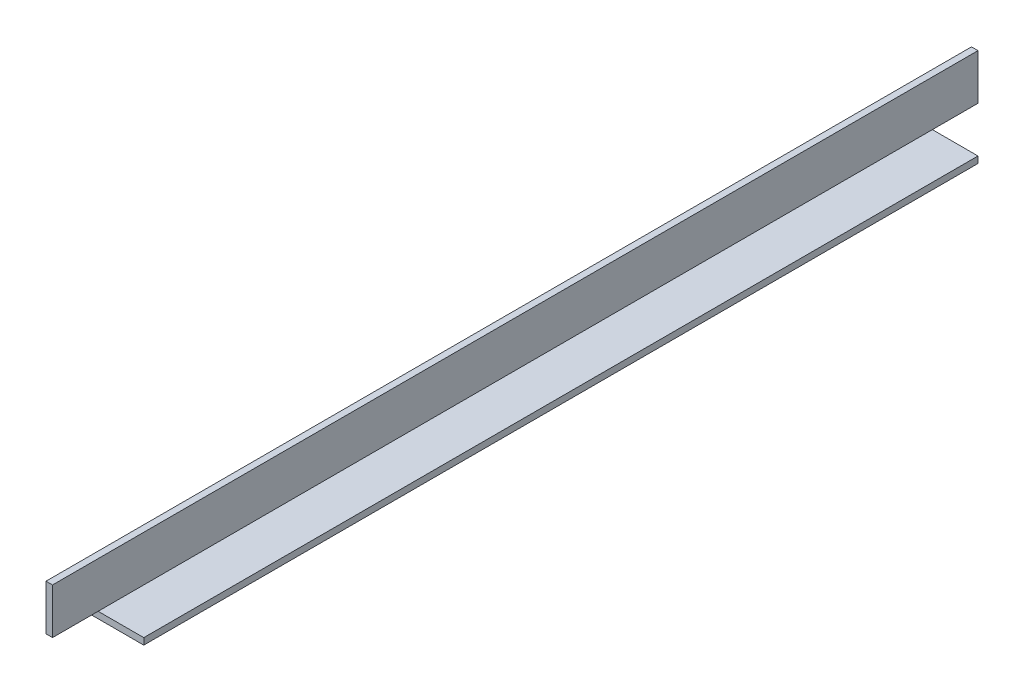
from build123d import *

# Parameters (mm, degrees)
BOSS_EXTRUDE1_DEPTH = 450.85
SKETCH2_W           = 22.225
SKETCH2_H           = 3.175
CUT_EXTRUDE1_DEPTH  = 26.4


with BuildPart() as part:
    # Sketch1 → Boss-Extrude1 (new body)
    with BuildSketch(Plane.XY):
        Polygon((0, 0), (0, 25.4), (3.175, 25.4), (3.175, 3.175), (25.4, 3.175), (25.4, 0), align=None)
    extrude(amount=BOSS_EXTRUDE1_DEPTH)

    # Sketch2 → Cut-Extrude1 (cut, through all)
    with BuildSketch(Plane(origin=(25.4, 0, 0), x_dir=(0, 0, -1), z_dir=(1, 0, 0))):
        with Locations((-439.7375, 1.5875)):
            Rectangle(SKETCH2_W, SKETCH2_H)
        with Locations((-11.1125, 1.5875)):
            Rectangle(SKETCH2_W, SKETCH2_H)
    extrude(amount=-CUT_EXTRUDE1_DEPTH, mode=Mode.SUBTRACT)


solid = part.part
